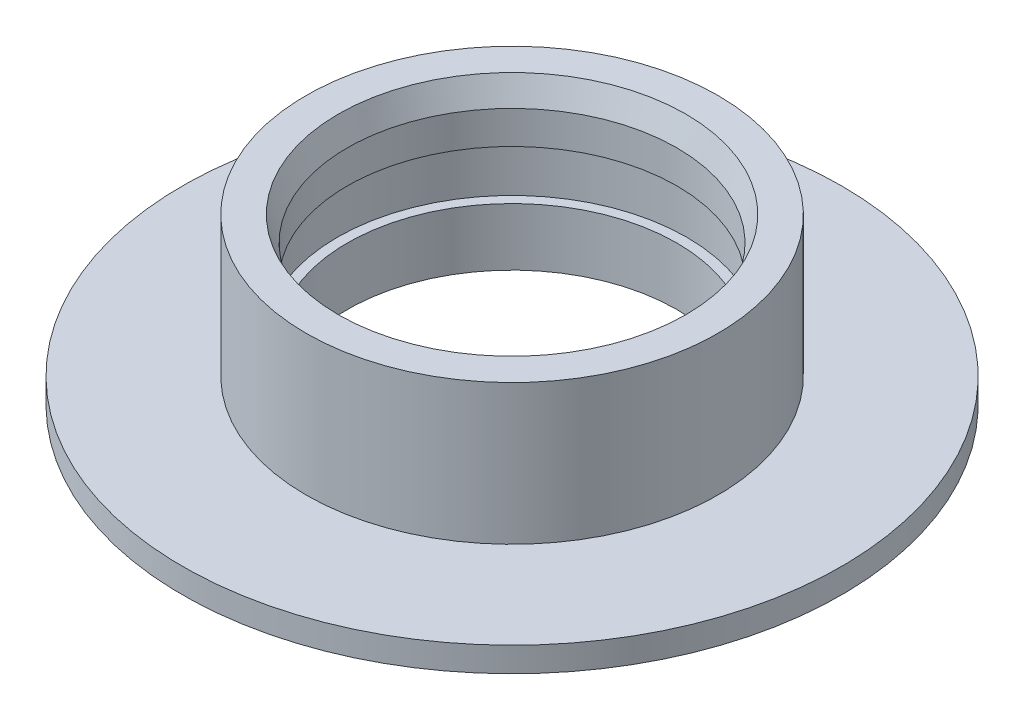
from build123d import *


with BuildPart() as part:
    # Esboço1 → Revolução1 (revolve)
    with BuildSketch(Plane.XY):
        Polygon((100, 0), (100, 35), (106, 35), (106, 65), (100, 65), (100, 85), (105.459553514, 100), (125, 100), (125, 15), (200, 15), (200, 0), align=None)
    revolve(axis=Axis((0, 0, 0), (0, 1, 0)))


solid = part.part
